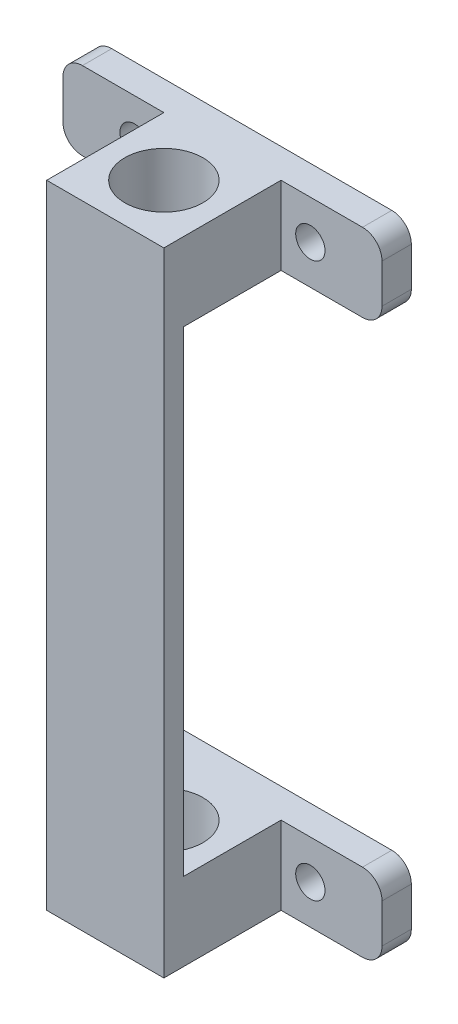
from build123d import *

# Parameters (mm, degrees)
SKETCH_1_W             = 32.677388302
SKETCH_1_H             = 8
EXTRUDE_1_DEPTH        = 3
SKETCH_2_R             = 1.5
CUT_EXTRUDE_1_DEPTH    = 4
SKETCH_3_R             = 6
EXTRUDE_2_DEPTH        = 8
EXTRUDE_3_DEPTH        = 8
SKETCH_10_W            = 12
SKETCH_10_H            = 24.37
EXTRUDE_5_DEPTH        = 2
SKETCH_4_R             = 4
CUT_EXTRUDE_2_DEPTH    = 9
FILLET_1_R             = 2
MIRROR_3_COPY_1_DEPTH  = 8
FILLET_1_OF_MIRROR_3_R = 2


with BuildPart() as part:
    # 草图1 → 凸台-拉伸1 (new body)
    with BuildSketch(Plane.XY):
        with Locations((-3.726697353, 26.358574689)):
            Rectangle(SKETCH_1_W, SKETCH_1_H)
    extrude_1 = extrude(amount=-EXTRUDE_1_DEPTH)

    # 草图2 → 切除-拉伸1 (cut, through all)
    with BuildSketch(Plane.XY):
        with Locations((-12.726697353, 26.358574689)):
            Circle(SKETCH_2_R)
        with Locations((5.273302647, 26.358574689)):
            Circle(SKETCH_2_R)
    cut_extrude_1 = extrude(amount=-CUT_EXTRUDE_1_DEPTH, mode=Mode.SUBTRACT)



with BuildPart() as body_2:
    # 草图3 → 凸台-拉伸2 (new body)
    with BuildSketch(Plane.XZ.offset(-22.358574689)):
        with Locations((-3.726697353, 6)):
            Circle(SKETCH_3_R)
    extrude_2 = extrude(amount=-EXTRUDE_2_DEPTH)


with BuildPart() as part_1:
    add(part.part)

    add(body_2.part)  # 凸台-拉伸3 merges body 2
    # 草图5 → 凸台-拉伸3 (add)
    with BuildSketch(Plane.XZ.offset(-22.358574689)):
        Polygon((-3.726697353, 0), (-9.726697353, 6), (-9.726697353, 0), align=None)
        Polygon((2.273302647, 6), (-3.726697353, 0), (2.273302647, 0), align=None)
    extrude_3 = extrude(amount=-EXTRUDE_3_DEPTH)

    # 镜向1: 凸台-拉伸3 across plane
    add(extrude_3.mirror(Plane(origin=(0, 0, 6), x_dir=(1, 0, 0), z_dir=(0, 0, -1))))

    # 草图10 → 凸台-拉伸5 (add)
    with BuildSketch(Plane.XY.offset(12)):
        with Locations((-3.726697353, 10.173574689)):
            Rectangle(SKETCH_10_W, SKETCH_10_H)
    extrude_5 = extrude(amount=-EXTRUDE_5_DEPTH)

    # 草图4 → 切除-拉伸2 (cut, through all)
    with BuildSketch(Plane.XZ.offset(-22.358574689)):
        with Locations((-3.726697353, 6)):
            Circle(SKETCH_4_R)
    cut_extrude_2 = extrude(amount=-CUT_EXTRUDE_2_DEPTH, mode=Mode.SUBTRACT)

    # 圆角1
    fillet_1_edges = [part_1.edges().sort_by_distance(p)[0] for p in [
        (12.611996798, 22.358574689, -1.5),
        (-20.065391504, 22.358574689, -1.5),
        (-20.065391504, 30.358574689, -1.5),
        (12.611996798, 30.358574689, -1.5),
    ]]
    fillet(fillet_1_edges, radius=FILLET_1_R)

    # 镜向3: 凸台-拉伸1, 切除-拉伸1, 凸台-拉伸2, 切除-拉伸2, 凸台-拉伸3, 凸台-拉伸5 across plane
    add(extrude_1.mirror(Plane(origin=(-9.726697353, -2.011425311, 10), x_dir=(0, 0, 1), z_dir=(0, -1, 0))))
    add(cut_extrude_1.mirror(Plane(origin=(-9.726697353, -2.011425311, 10), x_dir=(0, 0, 1), z_dir=(0, -1, 0))), mode=Mode.SUBTRACT)
    add(extrude_2.mirror(Plane(origin=(-9.726697353, -2.011425311, 10), x_dir=(0, 0, 1), z_dir=(0, -1, 0))))
    add(cut_extrude_2.mirror(Plane(origin=(-9.726697353, -2.011425311, 10), x_dir=(0, 0, 1), z_dir=(0, -1, 0))), mode=Mode.SUBTRACT)
    add(extrude_3.mirror(Plane(origin=(-9.726697353, -2.011425311, 10), x_dir=(0, 0, 1), z_dir=(0, -1, 0))))
    add(extrude_5.mirror(Plane(origin=(-9.726697353, -2.011425311, 10), x_dir=(0, 0, 1), z_dir=(0, -1, 0))))

    # 镜向3 copy 1 sketch → 镜向3 copy 1 (add)
    with BuildSketch(Plane(origin=(0, -26.381425311, 12), x_dir=(1, 0, 0), z_dir=(0, 1, 0))):
        Polygon((-3.726697353, 0), (-9.726697353, 6), (-9.726697353, 0), align=None)
        Polygon((2.273302647, 6), (-3.726697353, 0), (2.273302647, 0), align=None)
    extrude(amount=-MIRROR_3_COPY_1_DEPTH)

    # 圆角1 of 镜向3
    fillet_1_of_mirror_3_edges = [part_1.edges().sort_by_distance(p)[0] for p in [
        (12.611996798, -26.381425311, -1.5),
        (-20.065391504, -26.381425311, -1.5),
        (-20.065391504, -34.381425311, -1.5),
        (12.611996798, -34.381425311, -1.5),
    ]]
    fillet(fillet_1_of_mirror_3_edges, radius=FILLET_1_OF_MIRROR_3_R)


solid = part_1.part
